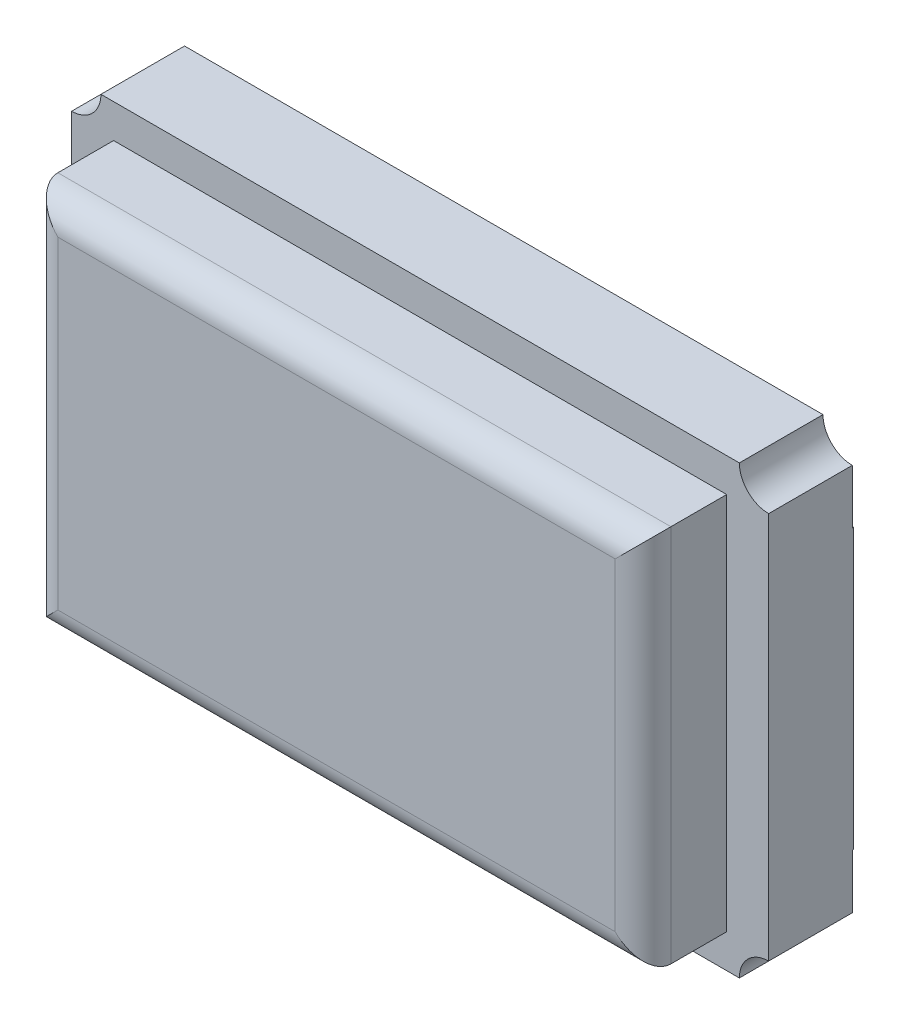
from build123d import *

# Parameters (mm, degrees)
BOSS_EXTRUDE1_DEPTH = 0.6
SKETCH2_W           = 4.397756064
SKETCH2_H           = 2.716261098
BOSS_EXTRUDE2_DEPTH = 0.6
SKETCH3_W           = 1.1
SKETCH3_H           = 2
BOSS_EXTRUDE3_DEPTH = 0.01
FILLET1_R           = 0.2


with BuildPart() as part:
    # Sketch1 → Boss-Extrude1 (new body)
    with BuildSketch(Plane.XY):
        with BuildLine():
            Line((-2.289923712, 1.6), (2.289923712, 1.6))
            ThreePointArc((2.289923712, 1.6), (2.351453632, 1.451453632), (2.5, 1.389923712))
            Line((2.5, 1.389923712), (2.5, -1.389923712))
            ThreePointArc((2.5, -1.389923712), (2.351453632, -1.451453632), (2.289923712, -1.6))
            Line((2.289923712, -1.6), (-2.289923712, -1.6))
            ThreePointArc((-2.289923712, -1.6), (-2.351453632, -1.451453632), (-2.5, -1.389923712))
            Line((-2.5, -1.389923712), (-2.5, 1.389923712))
            ThreePointArc((-2.5, 1.389923712), (-2.351453632, 1.451453632), (-2.289923712, 1.6))
        make_face()
    extrude(amount=BOSS_EXTRUDE1_DEPTH)

    # Sketch2 → Boss-Extrude2 (add)
    with BuildSketch(Plane.XY.offset(0.6)):
        Rectangle(SKETCH2_W, SKETCH2_H)
    extrude(amount=BOSS_EXTRUDE2_DEPTH)

    # Sketch3 → Boss-Extrude3 (add)
    with BuildSketch(Plane(origin=(0, 0, 0), x_dir=(-1, 0, 0), z_dir=(0, 0, -1))):
        with Locations((-1.95, 0)):
            Rectangle(SKETCH3_W, SKETCH3_H)
        with Locations((1.95, 0)):
            Rectangle(SKETCH3_W, SKETCH3_H)
    extrude(amount=BOSS_EXTRUDE3_DEPTH)

    # Fillet1
    fillet1_edges = [part.edges().sort_by_distance(p)[0] for p in [
        (2.198878032, 0, 1.2),
        (0, 1.358130549, 1.2),
        (-2.198878032, 0, 1.2),
        (0, -1.358130549, 1.2),
    ]]
    fillet(fillet1_edges, radius=FILLET1_R)


solid = part.part
